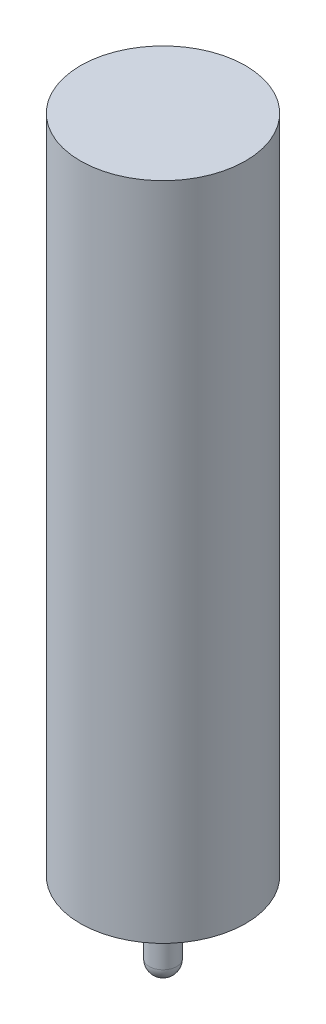
from build123d import *

# Parameters (mm, degrees)
SKETCH_1_R      = 1.5
EXTRUDE_2_DEPTH = 24
SKETCH_3_R      = 0.5
EXTRUDE_3_DEPTH = 3.1
FILLET_1_R      = 0.5
SKETCH_4_R      = 3
EXTRUDE_4_DEPTH = 24


with BuildPart() as part:
    # ｽｹｯﾁ1 → ﾎﾞｽ - 押し出し2 (new body)
    with BuildSketch(Plane(origin=(0, 0, 0), x_dir=(1, 0, 0), z_dir=(0, 1, 0))):
        Circle(SKETCH_1_R)
    extrude(amount=EXTRUDE_2_DEPTH)

    # ｽｹｯﾁ3 → ﾎﾞｽ - 押し出し3 (add)
    with BuildSketch(Plane.XZ):
        Circle(SKETCH_3_R)
    extrude(amount=EXTRUDE_3_DEPTH)

    # ﾌｨﾚｯﾄ1
    fillet_1_edges = [part.edges().sort_by_distance(p)[0] for p in [
        (-0.5, -3.1, 0),
    ]]
    fillet(fillet_1_edges, radius=FILLET_1_R)

    # ｽｹｯﾁ4 → ﾎﾞｽ - 押し出し4 (add)
    with BuildSketch(Plane(origin=(0, 24, 0), x_dir=(1, 0, 0), z_dir=(0, 1, 0))):
        Circle(SKETCH_4_R)
    extrude(amount=-EXTRUDE_4_DEPTH)


solid = part.part
